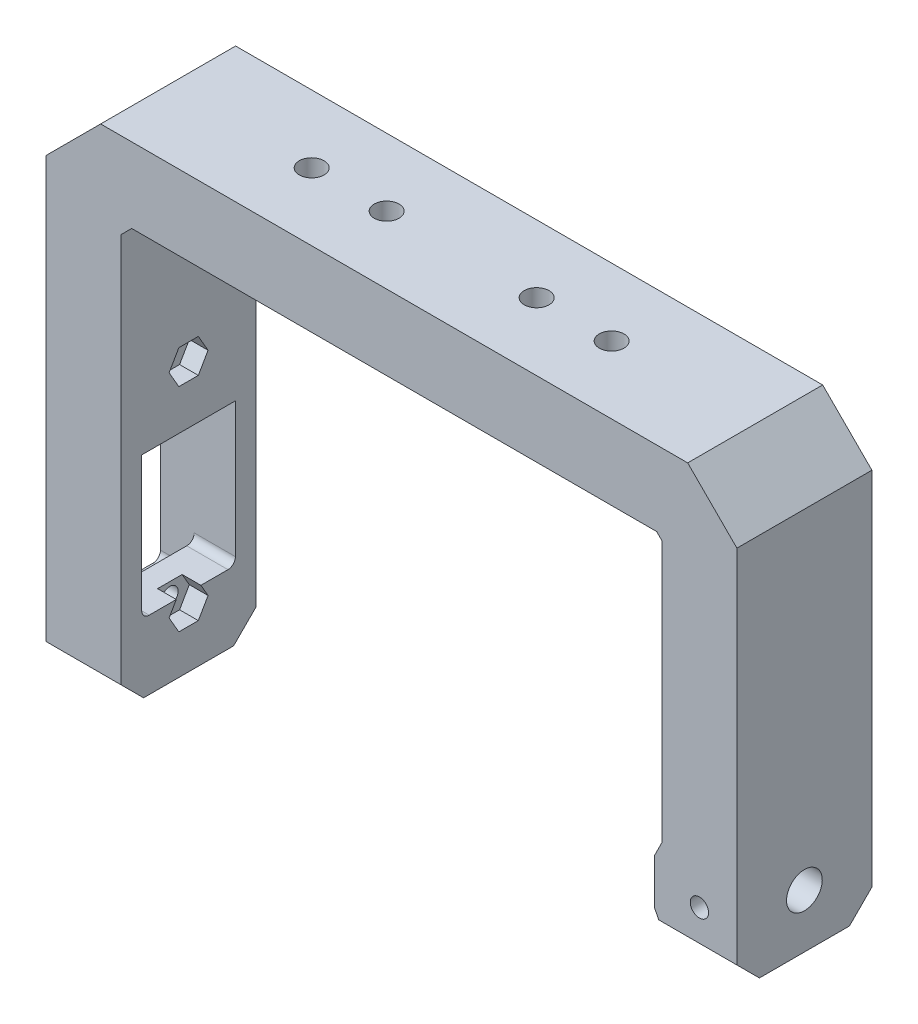
from build123d import *

# Parameters (mm, degrees)
BOSS_EXTRUDE1_DEPTH             = 9
SKETCH2_R                       = 0.5
CUT_EXTRUDE1_DEPTH              = 67.414213562
SKETCH9_R                       = 2.38125
PIN_HOLE_DEPTH                  = 93.121320344
SKETCH20_R                      = 1.21925
SPRING_PIN_DEPTH                = 10
SPRING_PIN_DEPTH_BACK           = 10
SKETCH32_W                      = 12.5
SKETCH32_H                      = 33.5
CUT_EXTRUDE11_DEPTH             = 4.5
CUT_EXTRUDE12_REACH             = 89.621
SKETCH33_W                      = 12.5
SKETCH33_H                      = 25
CUT_EXTRUDE13_REACH             = 89.621
SKETCH34_R                      = 1.1
FILLET1_R                       = 1
TAP_DRILL_FOR_M4X0_7_TAP1_D     = 3.3
TAP_DRILL_FOR_M4X0_7_TAP1_DEPTH = 66.414213562
SKETCH41_W                      = 12.5
SKETCH41_H                      = 6
BOSS_EXTRUDE4_DEPTH             = 3.5
CUT_EXTRUDE14_DEPTH             = 2.5
BOSS_EXTRUDE6_DEPTH             = 9
CHAMFER1_SIZE                   = 3
CUT_EXTRUDE15_REACH             = 84.121
SKETCH45_R                      = 2.38125


with BuildPart() as part:
    # Sketch1 → Boss-Extrude1 (new body, symmetric)
    with BuildSketch(Plane.XY):
        Polygon((-35, 0), (35, 0), (35.707106781, -0.707106781), (35.707106781, -47.707106781), (45.707106781, -47.707106781), (45.707106781, 3.435028843), (39.142135624, 10), (-39.142135624, 10), (-46.414213562, 2.727922061), (-46.414213562, -56.414213562), (-36.414213562, -56.414213562), (-36.414213562, -1.414213562), align=None)
    extrude(amount=BOSS_EXTRUDE1_DEPTH, both=True)

    # Sketch2 → Cut-Extrude1 (cut, through all)
    with BuildSketch(Plane(origin=(0, 10, 0), x_dir=(1, 0, 0), z_dir=(0, 1, 0))):
        with Locations((-10, 0)):
            Circle(SKETCH2_R)
        with Locations((10, 0)):
            Circle(SKETCH2_R)
        with Locations((-20, 0)):
            Circle(SKETCH2_R)
        with Locations((20, 0)):
            Circle(SKETCH2_R)
    extrude(amount=-CUT_EXTRUDE1_DEPTH, mode=Mode.SUBTRACT)

    # Sketch9 → Pin Hole (cut, through all)
    with BuildSketch(Plane(origin=(45.707106781, 0, 0), x_dir=(0, 0, -1), z_dir=(1, 0, 0))):
        with Locations((0, -40.564971157)):
            Circle(SKETCH9_R)
    extrude(amount=-PIN_HOLE_DEPTH, mode=Mode.SUBTRACT)

    # Sketch20 → spring pin (cut, two sides)
    with BuildSketch(Plane.XY) as spring_pin_sk:
        with Locations((40.707106781, -40.564971157)):
            Circle(SKETCH20_R)
    extrude(amount=SPRING_PIN_DEPTH, mode=Mode.SUBTRACT)
    extrude(spring_pin_sk.sketch, amount=-SPRING_PIN_DEPTH_BACK, mode=Mode.SUBTRACT)

    # Sketch32 → Cut-Extrude11 (cut)
    with BuildSketch(Plane.ZY.offset(46.414213562)):
        with Locations((0, -34.734971157)):
            Rectangle(SKETCH32_W, SKETCH32_H)
    extrude(amount=-CUT_EXTRUDE11_DEPTH, mode=Mode.SUBTRACT)

    # Sketch33 → Cut-Extrude12 (cut, up to next)
    with BuildSketch(Plane.ZY.offset(41.914213562), mode=Mode.PRIVATE) as cut_extrude12_sk1:
        with Locations((0, -34.734971157)):
            Rectangle(SKETCH33_W, SKETCH33_H)
    cut_extrude12_tool1 = extrude(cut_extrude12_sk1.sketch, amount=-CUT_EXTRUDE12_REACH, mode=Mode.PRIVATE) & part.part
    add(cut_extrude12_tool1.solids().sort_by_distance((-41.914214, -34.734971, 0))[0], mode=Mode.SUBTRACT)

    # Sketch34 → Cut-Extrude13 (cut, up to next)
    with BuildSketch(Plane.ZY.offset(41.914213562), mode=Mode.PRIVATE) as cut_extrude13_sk1:
        with Locations((0, -20.574371157)):
            Circle(SKETCH34_R)
    cut_extrude13_tool1 = extrude(cut_extrude13_sk1.sketch, amount=-CUT_EXTRUDE13_REACH, mode=Mode.PRIVATE) & part.part
    add(cut_extrude13_tool1.solids().sort_by_distance((-41.914214, -20.574371, 0))[0], mode=Mode.SUBTRACT)
    # Sketch34 → Cut-Extrude13 (cut, up to next)
    with BuildSketch(Plane.ZY.offset(41.914213562), mode=Mode.PRIVATE) as cut_extrude13_sk2:
        with Locations((0, -48.895371157)):
            Circle(SKETCH34_R)
    cut_extrude13_tool2 = extrude(cut_extrude13_sk2.sketch, amount=-CUT_EXTRUDE13_REACH, mode=Mode.PRIVATE) & part.part
    add(cut_extrude13_tool2.solids().sort_by_distance((-41.914214, -48.895371, 0))[0], mode=Mode.SUBTRACT)

    # Fillet1
    fillet1_edges = [part.edges().sort_by_distance(p)[0] for p in [
        (-44.164213562, -17.984971157, 6.25),
        (-44.164213562, -51.484971157, 6.25),
        (-44.164213562, -51.484971157, -6.25),
        (-44.164213562, -17.984971157, -6.25),
        (-39.164213562, -22.234971157, -6.25),
        (-39.164213562, -47.234971157, -6.25),
        (-39.164213562, -47.234971157, 6.25),
        (-39.164213562, -22.234971157, 6.25),
    ]]
    fillet(fillet1_edges, radius=FILLET1_R)

    # Tap Drill for M4x0.7 Tap1
    with Locations(Plane(origin=(0, 10, 0), x_dir=(1, 0, 0), z_dir=(0, 1, 0))):
        with Locations((-20, 0), (20, 0), (-10, 0), (10, 0)):
            Hole(TAP_DRILL_FOR_M4X0_7_TAP1_D / 2, depth=TAP_DRILL_FOR_M4X0_7_TAP1_DEPTH)

    # Sketch41 → Boss-Extrude4 (add)
    with BuildSketch(Plane(origin=(-36.414213562, 0, 0), x_dir=(0, 0, -1), z_dir=(1, 0, 0))):
        with Locations((0, -25.234971157)):
            Rectangle(SKETCH41_W, SKETCH41_H)
    extrude(amount=-BOSS_EXTRUDE4_DEPTH)

    # Sketch43 → Cut-Extrude14 (cut)
    with BuildSketch(Plane(origin=(-36.414213562, 0, 0), x_dir=(0, 0, -1), z_dir=(1, 0, 0))):
        Polygon((-1.299038106, -22.824371157), (1.299038106, -22.824371157), (2.598076211, -20.574371157), (1.299038106, -18.324371157), (-1.299038106, -18.324371157), (-2.598076211, -20.574371157), align=None)
        Polygon((-1.299038106, -46.645371157), (-2.598076211, -48.895371157), (-1.299038106, -51.145371157), (1.299038106, -51.145371157), (2.598076211, -48.895371157), (1.299038106, -46.645371157), align=None)
    extrude(amount=-CUT_EXTRUDE14_DEPTH, mode=Mode.SUBTRACT)

    # Sketch44 → Boss-Extrude6 (add, symmetric)
    with BuildSketch(Plane.XY):
        Polygon((34.707106781, -37.564971157), (34.707106781, -40.564971157), (35.707106781, -40.564971157), (35.707106781, -35.564971157), align=None)
        Polygon((34.707106781, -40.564971157), (34.707106781, -43.564971157), (35.707106781, -45.564971157), (35.707106781, -40.564971157), align=None)
    extrude(amount=BOSS_EXTRUDE6_DEPTH, both=True)

    # Chamfer1
    chamfer1_edges = [part.edges().sort_by_distance(p)[0] for p in [
        (40.707106781, -47.707106781, -9),
        (40.707106781, -47.707106781, 9),
        (-41.414213562, -56.414213562, -9),
        (-41.414213562, -56.414213562, 9),
    ]]
    chamfer(chamfer1_edges, length=CHAMFER1_SIZE)

    # Sketch45 → Cut-Extrude15 (cut, up to next)
    with BuildSketch(Plane(origin=(35.707106781, 0, 0), x_dir=(0, 0, -1), z_dir=(1, 0, 0)), mode=Mode.PRIVATE) as cut_extrude15_sk1:
        with Locations((0, -40.564971157)):
            Circle(SKETCH45_R)
    cut_extrude15_tool1 = extrude(cut_extrude15_sk1.sketch, amount=-CUT_EXTRUDE15_REACH, mode=Mode.PRIVATE) & part.part
    add(cut_extrude15_tool1.solids().sort_by_distance((35.707107, -40.564971, 0))[0], mode=Mode.SUBTRACT)


solid = part.part
